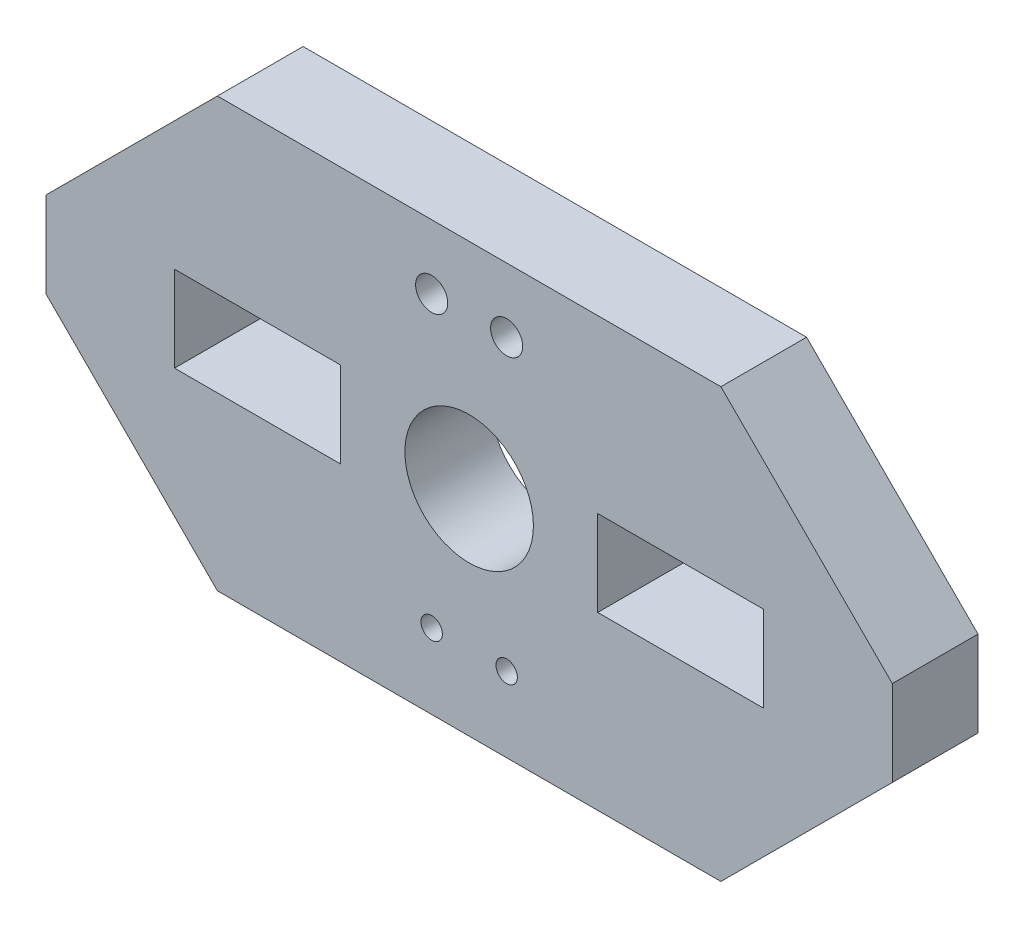
from build123d import *

# Parameters (mm, degrees)
SKETCH1_R           = 3
SKETCH1_R_2         = 0.75
SKETCH1_R_3         = 0.5
SKETCH1_W           = 7.75
SKETCH1_H           = 4
BOSS_EXTRUDE1_DEPTH = 4


with BuildPart() as part:
    # Sketch1 → Boss-Extrude1 (new body)
    with BuildSketch(Plane.XY):
        Polygon((8.000003067, 19.999998036), (31.500003067, 19.999998036), (39.500003067, 11.999998036), (39.500003067, 7.999998036), (31.500003067, -1.964e-06), (8.000003067, -1.964e-06), (3.067e-06, 7.999998036), (3.067e-06, 11.999998036), align=None)
        with Locations((19.750003067, 9.999998036)):
            Circle(SKETCH1_R, mode=Mode.SUBTRACT)
        with Locations((18.000003067, 16.999998036)):
            Circle(SKETCH1_R_2, mode=Mode.SUBTRACT)
        with Locations((21.500003067, 16.999998036)):
            Circle(SKETCH1_R_2, mode=Mode.SUBTRACT)
        with Locations((18.000003067, 3.499998036)):
            Circle(SKETCH1_R_3, mode=Mode.SUBTRACT)
        with Locations((21.500003067, 3.499998036)):
            Circle(SKETCH1_R_3, mode=Mode.SUBTRACT)
        with Locations((9.875003067, 9.999998036)):
            Rectangle(SKETCH1_W, SKETCH1_H, mode=Mode.SUBTRACT)
        with Locations((29.625003067, 9.999998036)):
            Rectangle(SKETCH1_W, SKETCH1_H, mode=Mode.SUBTRACT)
    extrude(amount=BOSS_EXTRUDE1_DEPTH)


solid = part.part
